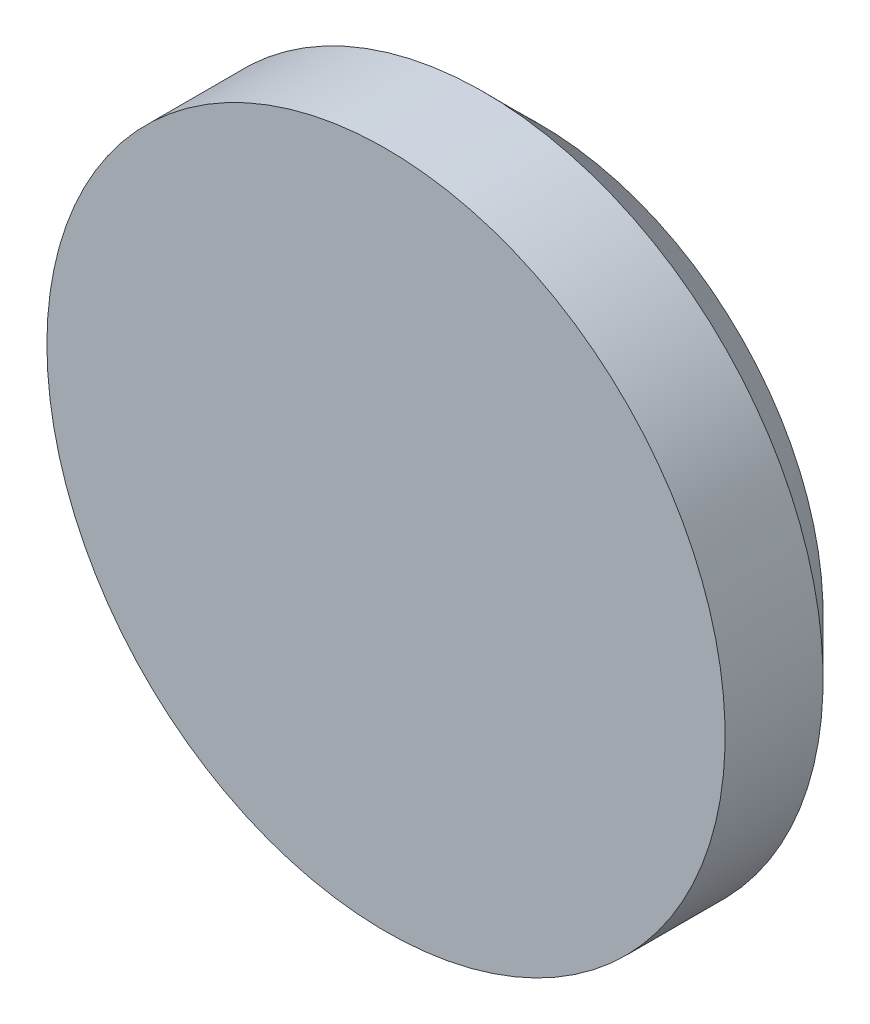
from build123d import *


with BuildPart() as part:
    # Sketch1 → Revolve1 (revolve)
    with BuildSketch(Plane(origin=(0, 0, 0), x_dir=(1, 0, 0), z_dir=(0, 1, 0))):
        Polygon((0, 0), (-9, 0), (-9, 2.6), (-7.5, 4.1), (0, 4.1), align=None)
    revolve(axis=Axis((0, 0, 0), (0, 0, 1)))


solid = part.part
